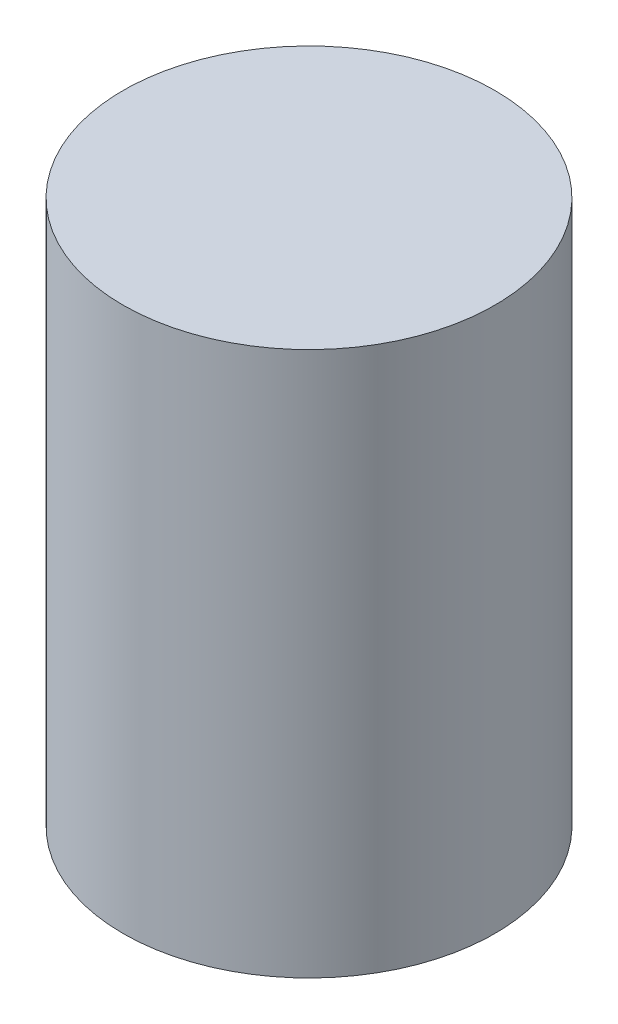
from build123d import *

# Parameters (mm, degrees)
SKETCH1_R           = 20.5
BOSS_EXTRUDE1_DEPTH = 60


with BuildPart() as part:
    # Sketch1 → Boss-Extrude1 (new body)
    with BuildSketch(Plane(origin=(0, 0, 0), x_dir=(1, 0, 0), z_dir=(0, 1, 0))):
        with Locations((2.600880996, 13.788975466)):
            Circle(SKETCH1_R)
    extrude(amount=BOSS_EXTRUDE1_DEPTH)


solid = part.part
